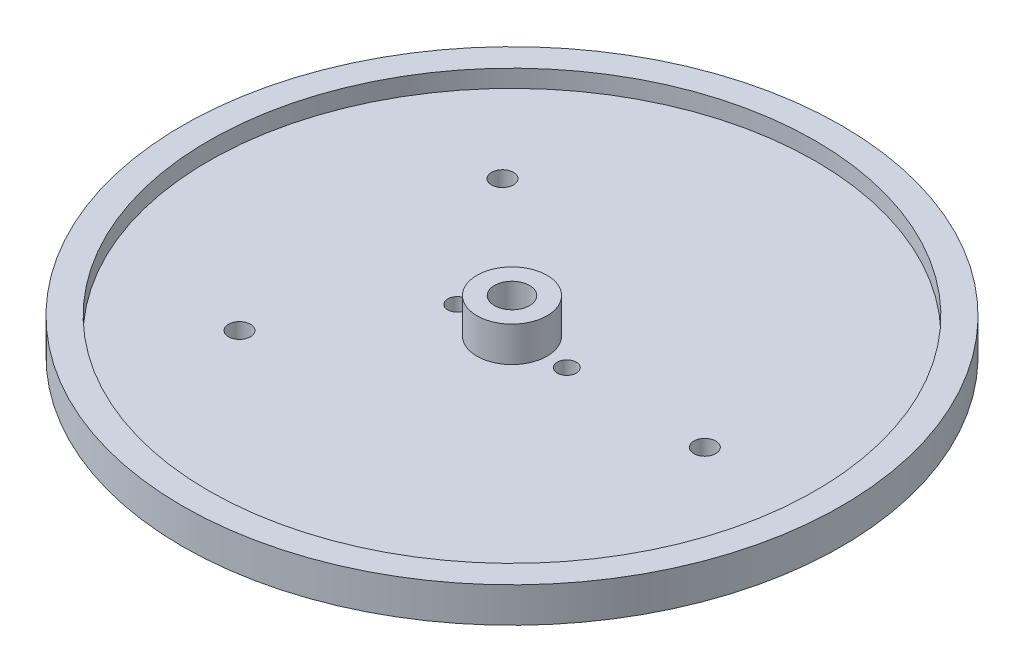
from build123d import *

# Parameters (mm, degrees)
SKETCH1_R          = 59.69
SKETCH1_R_2        = 3.175
EXTRUDE1_DEPTH     = 3.175
SKETCH2_R          = 59.69
SKETCH2_R_2        = 54.9275
EXTRUDE2_DEPTH     = 3.175
CUT_EXTRUDE1_REACH = 5.175
SKETCH3_R          = 1.984375
SKETCH3_R_2        = 1.7272
SKETCH4_R          = 6.35
SKETCH4_R_2        = 3.175
EXTRUDE3_DEPTH     = 6.35


with BuildPart() as part:
    # Sketch1 → Extrude1 (new body)
    with BuildSketch(Plane(origin=(0, 0, 0), x_dir=(1, 0, 0), z_dir=(0, 1, 0))):
        Circle(SKETCH1_R)
        Circle(SKETCH1_R_2, mode=Mode.SUBTRACT)
    extrude(amount=EXTRUDE1_DEPTH)

    # Sketch2 → Extrude2 (add)
    with BuildSketch(Plane(origin=(0, 3.175, 0), x_dir=(-1, 0, 0), z_dir=(0, 1, 0))):
        Circle(SKETCH2_R)
        Circle(SKETCH2_R_2, mode=Mode.SUBTRACT)
    extrude(amount=EXTRUDE2_DEPTH)

    # Sketch3 → Cut-Extrude1 (cut, up to next)
    with BuildSketch(Plane(origin=(0, 3.175, 0), x_dir=(-1, 0, 0), z_dir=(0, 1, 0)), mode=Mode.PRIVATE) as cut_extrude1_sk1:
        with Locations((25.542528029, -23.818792725)):
            Circle(SKETCH3_R)
    cut_extrude1_tool1 = extrude(cut_extrude1_sk1.sketch, amount=-CUT_EXTRUDE1_REACH, mode=Mode.PRIVATE) & part.part
    add(cut_extrude1_tool1.solids().sort_by_distance((-25.542528, 3.175, -23.818793))[0], mode=Mode.SUBTRACT)
    # Sketch3 → Cut-Extrude1 (cut, up to next)
    with BuildSketch(Plane(origin=(0, 3.175, 0), x_dir=(-1, 0, 0), z_dir=(0, 1, 0)), mode=Mode.PRIVATE) as cut_extrude1_sk2:
        with Locations((25.542528029, 23.818792725)):
            Circle(SKETCH3_R)
    cut_extrude1_tool2 = extrude(cut_extrude1_sk2.sketch, amount=-CUT_EXTRUDE1_REACH, mode=Mode.PRIVATE) & part.part
    add(cut_extrude1_tool2.solids().sort_by_distance((-25.542528, 3.175, 23.818793))[0], mode=Mode.SUBTRACT)
    # Sketch3 → Cut-Extrude1 (cut, up to next)
    with BuildSketch(Plane(origin=(0, 3.175, 0), x_dir=(-1, 0, 0), z_dir=(0, 1, 0)), mode=Mode.PRIVATE) as cut_extrude1_sk3:
        with Locations((-34.925, 0)):
            Circle(SKETCH3_R)
    cut_extrude1_tool3 = extrude(cut_extrude1_sk3.sketch, amount=-CUT_EXTRUDE1_REACH, mode=Mode.PRIVATE) & part.part
    add(cut_extrude1_tool3.solids().sort_by_distance((34.925, 3.175, 0))[0], mode=Mode.SUBTRACT)
    # Sketch3 → Cut-Extrude1 (cut, up to next)
    with BuildSketch(Plane(origin=(0, 3.175, 0), x_dir=(-1, 0, 0), z_dir=(0, 1, 0)), mode=Mode.PRIVATE) as cut_extrude1_sk4:
        with Locations((-9.921875, 0)):
            Circle(SKETCH3_R_2)
    cut_extrude1_tool4 = extrude(cut_extrude1_sk4.sketch, amount=-CUT_EXTRUDE1_REACH, mode=Mode.PRIVATE) & part.part
    add(cut_extrude1_tool4.solids().sort_by_distance((9.921875, 3.175, 0))[0], mode=Mode.SUBTRACT)
    # Sketch3 → Cut-Extrude1 (cut, up to next)
    with BuildSketch(Plane(origin=(0, 3.175, 0), x_dir=(-1, 0, 0), z_dir=(0, 1, 0)), mode=Mode.PRIVATE) as cut_extrude1_sk5:
        with Locations((9.921875, 0)):
            Circle(SKETCH3_R_2)
    cut_extrude1_tool5 = extrude(cut_extrude1_sk5.sketch, amount=-CUT_EXTRUDE1_REACH, mode=Mode.PRIVATE) & part.part
    add(cut_extrude1_tool5.solids().sort_by_distance((-9.921875, 3.175, 0))[0], mode=Mode.SUBTRACT)

    # Sketch4 → Extrude3 (add)
    with BuildSketch(Plane(origin=(0, 3.175, 0), x_dir=(-1, 0, 0), z_dir=(0, 1, 0))):
        Circle(SKETCH4_R)
        Circle(SKETCH4_R_2, mode=Mode.SUBTRACT)
    extrude(amount=EXTRUDE3_DEPTH)


solid = part.part
